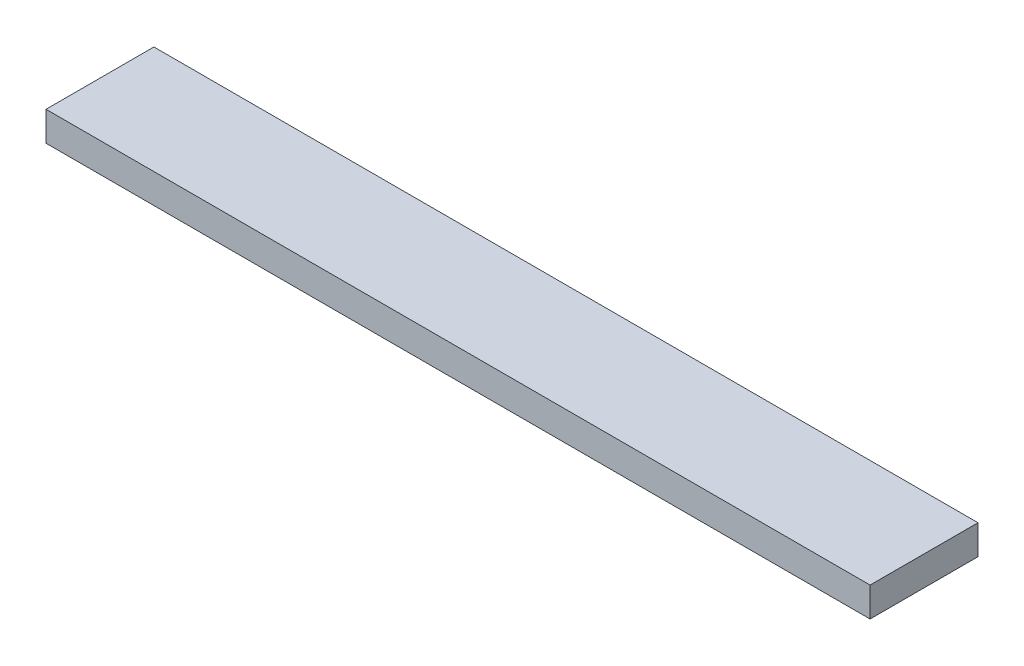
from build123d import *

# Parameters (mm, degrees)
SKETCH1_W           = 1066.8
SKETCH1_H           = 139.7
BOSS_EXTRUDE1_DEPTH = 38.1


with BuildPart() as part:
    # Sketch1 → Boss-Extrude1 (new body)
    with BuildSketch(Plane(origin=(0, 0, 0), x_dir=(1, 0, 0), z_dir=(0, 1, 0))):
        with Locations((533.4, 69.85)):
            Rectangle(SKETCH1_W, SKETCH1_H)
    extrude(amount=BOSS_EXTRUDE1_DEPTH)


solid = part.part
